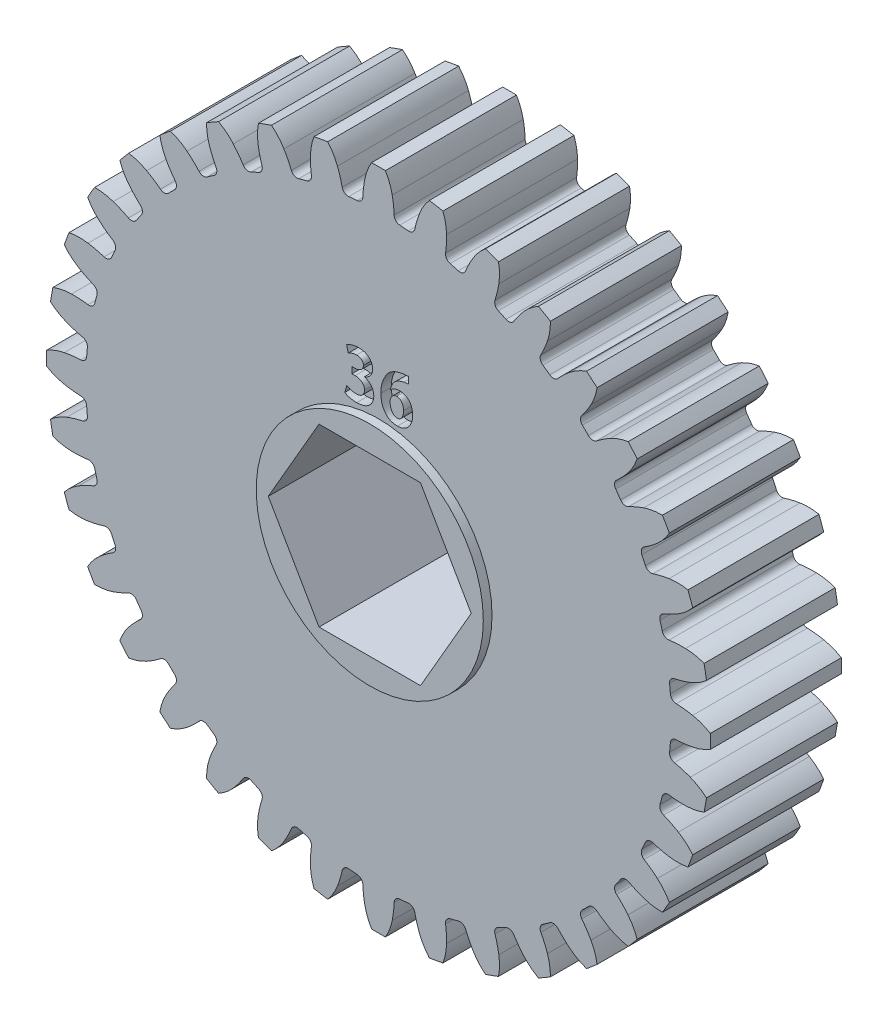
from build123d import *

# Parameters (mm, degrees)
SKETCH1_R            = 24.13
ROUND_STOCK_DEPTH    = 4.7625
SINGLE_TOOTH_DEPTH   = 36.429358236
TOOTH_PATTERN_COUNT  = 36
SKETCH4_R            = 8.255
TOPBEARINGBOSS_DEPTH = 0.635
ROUNDBORE_DEPTH      = 35.549194003
ROUNDBORE_DEPTH_BACK = 35.549194003
SKETCH5_R            = 6.3881
HEX_2_DEPTH          = 35.549194003
HEX_2_DEPTH_BACK     = 35.549194003
TOOTHCOUNT_DEPTH     = 0.762


with BuildPart() as part:
    # Sketch1 → Round Stock (new, symmetric)
    with BuildSketch(Plane.XY):
        Circle(SKETCH1_R)
    extrude(amount=ROUND_STOCK_DEPTH, both=True)

    # Sketch2 → Single Tooth (cut, through all)
    with BuildSketch(Plane.XY.offset(4.7625)):
        with BuildLine():
            ThreePointArc((-23.845709826, -3.693104775), (-24.038178065, -2.103068073), (-24.124740827, -0.503765842))
            ThreePointArc((-24.124740827, -0.503765842), (-23.502960299, -0.806631954), (-22.838222877, -0.997585))
            ThreePointArc((-22.838222877, -0.997585), (-22.243537068, -1.089742074), (-21.643459021, -1.135024237))
            ThreePointArc((-21.643459021, -1.135024237), (-21.351011668, -1.25921453), (-21.216180676, -1.546911048))
            ThreePointArc((-21.216180676, -1.546911048), (-21.191551715, -1.854020538), (-21.162477503, -2.160741118))
            ThreePointArc((-21.162477503, -2.160741118), (-21.245302134, -2.467480035), (-21.511741136, -2.640566549))
            ThreePointArc((-21.511741136, -2.640566549), (-22.094839484, -2.789363234), (-22.664487771, -2.983386341))
            ThreePointArc((-22.664487771, -2.983386341), (-23.28596769, -3.286868823), (-23.845709826, -3.693104775))
        make_face()
    single_tooth = extrude(amount=-SINGLE_TOOTH_DEPTH, mode=Mode.SUBTRACT)

    # Tooth Pattern: Single Tooth ×36 about axis
    tooth_pattern_axis = Axis((0, 0, 50), (0, 0, -1))
    for i in range(1, TOOTH_PATTERN_COUNT):
        add(single_tooth.rotate(tooth_pattern_axis, i * 360 / TOOTH_PATTERN_COUNT), mode=Mode.SUBTRACT)

    # Sketch4 → TopBearingBoss (add)
    with BuildSketch(Plane.XY.offset(4.7625)):
        Circle(SKETCH4_R)
    topbearingboss = extrude(amount=TOPBEARINGBOSS_DEPTH)

    # BottomBearingBoss: TopBearingBoss across plane
    add(topbearingboss.mirror(Plane.XY))

    # Sketch5 → RoundBore (cut, two sides: drawn at the far end of the back side and taken through both)
    with BuildSketch(Plane.XY.offset(-ROUNDBORE_DEPTH_BACK)):
        Circle(SKETCH5_R)
    extrude(amount=ROUNDBORE_DEPTH + ROUNDBORE_DEPTH_BACK, mode=Mode.SUBTRACT)

    # Sketch6 → Hex 2 (cut, two sides: drawn at the far end of the back side and taken through both)
    with BuildSketch(Plane.XY.offset(-HEX_2_DEPTH_BACK)):
        Polygon((3.688171255, 6.3881), (-3.688171255, 6.3881), (-7.376342509, 0), (-3.688171255, -6.3881), (3.688171255, -6.3881), (7.376342509, 0), align=None)
    extrude(amount=HEX_2_DEPTH + HEX_2_DEPTH_BACK, mode=Mode.SUBTRACT)

    # Sketch7 → ToothCount (cut)
    # profile 1 of 2: a face of its own
    with BuildSketch(Plane.XY.offset(4.7625)):
        with BuildLine():
            add(Edge.make_bspline(
                [(-2.196836906, 11.286278756), (-2.178915818, 11.297156055), (-2.141223827, 11.320033408), (-2.079049839, 11.350318156), (-2.010032763, 11.380926277), (-1.934762173, 11.410311036), (-1.854329878, 11.436168713), (-1.770263227, 11.455353767), (-1.683460919, 11.467360467), (-1.624659493, 11.4699095), (-1.594928356, 11.471198341)],
                knots=[0, 0, 0, 0, 0.789517344, 1.660528633, 2.603012169, 3.634206293, 4.703625655, 5.783272812, 6.879179917, 8, 8, 8, 8], degree=3))
            add(Edge.make_bspline(
                [(-1.594928356, 11.471198341), (-1.574460936, 11.470554656), (-1.534762177, 11.469306159), (-1.47713404, 11.463606686), (-1.423879336, 11.453477122), (-1.374283218, 11.441158677), (-1.328763048, 11.424951076), (-1.287884282, 11.404268463), (-1.250682209, 11.380957145), (-1.207632909, 11.345445565), (-1.162337367, 11.293728488), (-1.123737052, 11.221709264), (-1.099384551, 11.141044702), (-1.09719459, 11.08425001), (-1.096059578, 11.05481448)],
                knots=[0, 0, 0, 0, 1.002343817, 1.944153497, 2.831185645, 3.653858711, 4.444110717, 5.190523602, 5.892507091, 6.588768807, 7.916765639, 9.227316692, 10.562974774, 12, 12, 12, 12], degree=3))
            add(Edge.make_bspline(
                [(-1.096059578, 11.05481448), (-1.097577748, 11.03495677), (-1.100554269, 10.996023792), (-1.112699691, 10.940075039), (-1.129707477, 10.88785283), (-1.153031302, 10.839915598), (-1.182087741, 10.796142931), (-1.217177315, 10.756941781), (-1.256667361, 10.720722862), (-1.317771626, 10.680421456), (-1.398966259, 10.638714254), (-1.500733377, 10.602006649), (-1.605358693, 10.579218439), (-1.676201576, 10.576463643), (-1.711726998, 10.575082202)],
                knots=[0, 0, 0, 0, 0.826082647, 1.61961569, 2.370535654, 3.101700729, 3.826161143, 4.544435158, 5.281678469, 6.044172927, 7.575983875, 9.060899392, 10.526135799, 12, 12, 12, 12], degree=3))
            Line((-1.711726998, 10.575082202), (-1.930092284, 10.575741437))
            Line((-1.930092284, 10.575741437), (-1.930092284, 10.116465419))
            Line((-1.930092284, 10.116465419), (-1.697473218, 10.116465419))
            add(Edge.make_bspline(
                [(-1.697473218, 10.116465419), (-1.675382922, 10.115780753), (-1.631656679, 10.114425503), (-1.566825762, 10.10900903), (-1.504082821, 10.097360085), (-1.443435175, 10.082308135), (-1.384684626, 10.063366881), (-1.328755957, 10.038490645), (-1.274409443, 10.010378343), (-1.223022317, 9.977452657), (-1.175368974, 9.94023794), (-1.133494804, 9.897631047), (-1.097639058, 9.850707116), (-1.06816936, 9.798687509), (-1.044428595, 9.742258033), (-1.027698192, 9.680722473), (-1.015171602, 9.615212982), (-1.012808829, 9.569707458), (-1.011595023, 9.546330317)],
                knots=[0, 0, 0, 0, 1.060385101, 2.098960464, 3.117449411, 4.118233749, 5.096052482, 6.074383624, 7.051518727, 8.029280509, 8.998404297, 9.946146869, 10.88752235, 11.823439848, 12.807333282, 13.816263899, 14.87816903, 16, 16, 16, 16], degree=3))
            add(Edge.make_bspline(
                [(-1.011595023, 9.546330317), (-1.011865654, 9.528486901), (-1.012402597, 9.493084795), (-1.019998451, 9.441169552), (-1.031820529, 9.390924278), (-1.048936861, 9.342923732), (-1.071216041, 9.296953758), (-1.097218555, 9.252469587), (-1.12972688, 9.210937746), (-1.165309853, 9.170606621), (-1.206737658, 9.134079), (-1.25280534, 9.101643269), (-1.304179769, 9.074583526), (-1.360221912, 9.052217644), (-1.421012759, 9.033443704), (-1.487197189, 9.020778134), (-1.557974277, 9.011991685), (-1.606778844, 9.010140631), (-1.631881599, 9.009188537)],
                knots=[0, 0, 0, 0, 0.927962802, 1.841118252, 2.724136883, 3.611301861, 4.486942311, 5.380290724, 6.287036469, 7.227346462, 8.17619008, 9.154415755, 10.153127624, 11.190589993, 12.291550635, 13.459071236, 14.693066716, 16, 16, 16, 16], degree=3))
            add(Edge.make_bspline(
                [(-1.631881599, 9.009188537), (-1.665362091, 9.010379158), (-1.731664119, 9.012736967), (-1.829632894, 9.026224982), (-1.925378301, 9.043835659), (-2.016726815, 9.070022353), (-2.101885221, 9.099136161), (-2.178281918, 9.130048278), (-2.244835108, 9.161086619), (-2.284015729, 9.184838615), (-2.302319005, 9.195934389)],
                knots=[0, 0, 0, 0, 1.141993655, 2.261510849, 3.369504559, 4.459881496, 5.499111408, 6.438152545, 7.270381037, 8, 8, 8, 8], degree=3))
            Line((-2.302319005, 9.195934389), (-2.452261762, 8.684039438))
            add(Edge.make_bspline(
                [(-2.452261762, 8.684039438), (-2.428529877, 8.669357088), (-2.378233874, 8.638240153), (-2.292723153, 8.600830484), (-2.196474521, 8.564578926), (-2.089158441, 8.533792754), (-1.972966584, 8.507184261), (-1.849451555, 8.488462121), (-1.719665395, 8.476274829), (-1.631029969, 8.474350747), (-1.585690045, 8.473366516)],
                knots=[0, 0, 0, 0, 0.741190489, 1.570836841, 2.475795164, 3.475217062, 4.536537938, 5.643313588, 6.794477705, 8, 8, 8, 8], degree=3))
            add(Edge.make_bspline(
                [(-1.585690045, 8.473366516), (-1.537038073, 8.475140584), (-1.442349194, 8.478593362), (-1.304871939, 8.494333335), (-1.176257502, 8.519386582), (-1.056333753, 8.552935857), (-0.944728287, 8.594990317), (-0.842131695, 8.646565865), (-0.748066187, 8.706870718), (-0.663867654, 8.776373864), (-0.588711388, 8.852179588), (-0.522881774, 8.932982894), (-0.467152229, 9.018581512), (-0.421085215, 9.108670247), (-0.386357614, 9.203915239), (-0.360187511, 9.303221033), (-0.345085184, 9.4075216), (-0.342481777, 9.478536229), (-0.341157617, 9.514656109)],
                knots=[0, 0, 0, 0, 1.283230384, 2.49748659, 3.643929247, 4.734473942, 5.777057172, 6.783347331, 7.756557876, 8.716669339, 9.655743054, 10.566896716, 11.459630034, 12.344036494, 13.228461966, 14.127277565, 15.047484865, 16, 16, 16, 16], degree=3))
            add(Edge.make_bspline(
                [(-0.341157617, 9.514656109), (-0.342240041, 9.543504424), (-0.344354072, 9.599846698), (-0.355159789, 9.682148201), (-0.371536738, 9.760302853), (-0.393953784, 9.834546146), (-0.422410685, 9.904469492), (-0.456085487, 9.970635783), (-0.496495171, 10.031862162), (-0.542348497, 10.088757427), (-0.592137515, 10.141156982), (-0.645270919, 10.188796041), (-0.70070077, 10.232144743), (-0.759877188, 10.269770266), (-0.821926986, 10.302764875), (-0.886816291, 10.331072198), (-0.954333296, 10.355432631), (-1.001132443, 10.366768294), (-1.024792609, 10.372499246)],
                knots=[0, 0, 0, 0, 1.164005744, 2.273364363, 3.343604564, 4.382148734, 5.397114869, 6.385236831, 7.372083179, 8.350396341, 9.329473701, 10.284453012, 11.226859979, 12.164619053, 13.109320557, 14.058884727, 15.018633619, 16, 16, 16, 16], degree=3))
            Line((-1.024792609, 10.372499246), (-1.024619262, 10.381435327))
            add(Edge.make_bspline(
                [(-1.024619262, 10.381435327), (-1.000782815, 10.390213261), (-0.953943817, 10.407462042), (-0.887288613, 10.438702827), (-0.82492571, 10.473134486), (-0.766912611, 10.510610789), (-0.713304918, 10.551186008), (-0.663192206, 10.59389436), (-0.618612577, 10.640946391), (-0.578102521, 10.690491075), (-0.542541765, 10.742709757), (-0.51136231, 10.796953051), (-0.484940117, 10.853248236), (-0.462902155, 10.911387676), (-0.446558127, 10.97178571), (-0.434690991, 11.033989365), (-0.427235547, 11.098187454), (-0.426164403, 11.141678607), (-0.425622172, 11.16369457)],
                knots=[0, 0, 0, 0, 1.153913132, 2.267457648, 3.341260607, 4.389305308, 5.402891048, 6.394955316, 7.377659085, 8.344009373, 9.300538721, 10.245296245, 11.184325342, 12.123779964, 13.067108642, 14.023794665, 14.999611132, 16, 16, 16, 16], degree=3))
            add(Edge.make_bspline(
                [(-0.425622172, 11.16369457), (-0.426366913, 11.192331555), (-0.427840032, 11.248976366), (-0.440013671, 11.332106293), (-0.459591608, 11.411821864), (-0.488010301, 11.487580561), (-0.522487963, 11.560696423), (-0.566830535, 11.62934768), (-0.617838522, 11.695132733), (-0.67648039, 11.757205999), (-0.743001822, 11.814036857), (-0.817489119, 11.863701359), (-0.899346405, 11.906174453), (-0.988972012, 11.941155134), (-1.086136015, 11.968304764), (-1.190339529, 11.989811767), (-1.302292027, 12.002801474), (-1.379554875, 12.005584906), (-1.419400452, 12.007020362)],
                knots=[0, 0, 0, 0, 0.938614469, 1.856607385, 2.748736139, 3.624980026, 4.505635583, 5.394024719, 6.298603057, 7.232244148, 8.189000026, 9.161181486, 10.161216018, 11.207242686, 12.309896165, 13.465529691, 14.6929367, 16, 16, 16, 16], degree=3))
            add(Edge.make_bspline(
                [(-1.419400452, 12.007020362), (-1.465622688, 12.005609431), (-1.556286215, 12.002841931), (-1.689776389, 11.989048547), (-1.817579323, 11.965815744), (-1.938844915, 11.935282334), (-2.050442449, 11.897929795), (-2.151912406, 11.860147691), (-2.2402274, 11.817159271), (-2.293082812, 11.784809656), (-2.318156109, 11.769463801)],
                knots=[0, 0, 0, 0, 1.17932827, 2.313217001, 3.419264874, 4.49021776, 5.499784981, 6.419836909, 7.250409829, 8, 8, 8, 8], degree=3))
            Line((-2.318156109, 11.769463801), (-2.196836906, 11.286278756))
        make_face()
    # profile 2 of 2: a face of its own
    with BuildSketch(Plane.XY.offset(4.7625)):
        with BuildLine():
            add(Edge.make_bspline(
                [(2.16522585, 12.011638873), (2.116090977, 12.008719227), (2.019932735, 12.003005404), (1.879031609, 11.988190007), (1.744404434, 11.969563186), (1.615928082, 11.944746803), (1.493296301, 11.916256978), (1.377056529, 11.881820359), (1.267150023, 11.842813368), (1.163127743, 11.799470705), (1.06544998, 11.750394794), (0.973311698, 11.69728536), (0.888067039, 11.638121618), (0.808393868, 11.574734504), (0.735107827, 11.506119033), (0.66828399, 11.43244516), (0.607036737, 11.354374643), (0.5355791, 11.244205041), (0.457579729, 11.10304908), (0.374719808, 10.933851292), (0.305310899, 10.765916944), (0.251550554, 10.59885633), (0.208961641, 10.433802856), (0.182167599, 10.269504161), (0.16815263, 10.10659293), (0.169993557, 9.998589698), (0.170908748, 9.944897436)],
                knots=[0, 0, 0, 0, 1.090744659, 2.134616076, 3.139087949, 4.101859546, 5.033610514, 5.928252281, 6.787073956, 7.617306137, 8.423946315, 9.20820989, 9.972212763, 10.721358476, 11.46286786, 12.194455914, 12.923864343, 13.659388525, 15.102127992, 16.495300966, 17.833290996, 19.125159406, 20.3819783, 21.607356425, 22.810531475, 24, 24, 24, 24], degree=3))
            add(Edge.make_bspline(
                [(0.170908748, 9.944897436), (0.171997744, 9.892514966), (0.174134233, 9.78974636), (0.188649927, 9.639315699), (0.212957804, 9.496400409), (0.246768717, 9.360970325), (0.289364177, 9.232497762), (0.342284126, 9.11153069), (0.404530359, 8.997823002), (0.476280219, 8.892606751), (0.556253323, 8.796074997), (0.646930208, 8.712892587), (0.74493695, 8.640290295), (0.853419233, 8.582462824), (0.969543075, 8.535086828), (1.095117815, 8.50193965), (1.228807739, 8.479552879), (1.321205658, 8.475463604), (1.368589744, 8.473366516)],
                knots=[0, 0, 0, 0, 1.177116803, 2.309372851, 3.392628795, 4.432051096, 5.443402761, 6.430645545, 7.395204453, 8.352184711, 9.288881539, 10.205312589, 11.110962038, 12.02225958, 12.960363956, 13.923249514, 14.93498766, 16, 16, 16, 16], degree=3))
            add(Edge.make_bspline(
                [(1.368589744, 8.473366516), (1.411342146, 8.475627545), (1.494855157, 8.480044265), (1.616154334, 8.500289552), (1.730496415, 8.530200645), (1.837131605, 8.572251106), (1.936937945, 8.623784428), (2.029502145, 8.686221567), (2.114080207, 8.760027545), (2.191092047, 8.843287057), (2.260069439, 8.934026113), (2.320041648, 9.030515295), (2.371318782, 9.131318333), (2.412946872, 9.237013093), (2.445952513, 9.347143913), (2.469760612, 9.462156485), (2.48434098, 9.58159847), (2.487038427, 9.66286909), (2.488404977, 9.704041478)],
                knots=[0, 0, 0, 0, 1.104921001, 2.158364753, 3.169783988, 4.151903943, 5.11232811, 6.06555167, 7.028006494, 8.004772461, 8.989828801, 9.967123232, 10.935061221, 11.906609782, 12.896893828, 13.900706794, 14.936480177, 16, 16, 16, 16], degree=3))
            add(Edge.make_bspline(
                [(2.488404977, 9.704041478), (2.487102095, 9.745881011), (2.48455711, 9.827608231), (2.469523147, 9.946206312), (2.448078109, 10.057696411), (2.418845379, 10.161816269), (2.379826724, 10.257961894), (2.334938543, 10.347771075), (2.280123752, 10.429155525), (2.218771813, 10.503330003), (2.151003727, 10.569225308), (2.077669646, 10.626225584), (2.000468227, 10.67560012), (1.917922724, 10.715240078), (1.831199903, 10.746308044), (1.739908608, 10.76882408), (1.644189086, 10.782885995), (1.578699174, 10.785112677), (1.545437406, 10.78624359)],
                knots=[0, 0, 0, 0, 1.24489772, 2.431720048, 3.552250136, 4.621151083, 5.643244016, 6.635503114, 7.602998542, 8.555771906, 9.495326128, 10.409157675, 11.315198569, 12.216760831, 13.127634607, 14.051465654, 15.010356011, 16, 16, 16, 16], degree=3))
            add(Edge.make_bspline(
                [(1.545437406, 10.78624359), (1.509533826, 10.784938902), (1.439385005, 10.782389788), (1.337057078, 10.767272191), (1.240760281, 10.741486208), (1.151132542, 10.705717889), (1.068167776, 10.662105476), (0.992734761, 10.610948247), (0.923863705, 10.553647343), (0.884193251, 10.509806048), (0.864441931, 10.48797813)],
                knots=[0, 0, 0, 0, 1.123065688, 2.194258491, 3.227237041, 4.233902505, 5.206347761, 6.152747248, 7.080280743, 8, 8, 8, 8], degree=3))
            add(Edge.make_bspline(
                [(0.864441931, 10.48797813), (0.861826889, 10.493829502), (0.855215586, 10.508622843), (0.85772762, 10.53916287), (0.865853204, 10.579165289), (0.882804349, 10.630026603), (0.904993373, 10.69229104), (0.935706115, 10.765181241), (0.973828248, 10.848981827), (1.016388606, 10.942574064), (1.070734007, 11.038505241), (1.14235549, 11.127327846), (1.228216905, 11.208074416), (1.328312123, 11.280592801), (1.443170541, 11.34450425), (1.57161643, 11.401286865), (1.714859819, 11.449432081), (1.81621044, 11.473758241), (1.868778281, 11.486375566)],
                knots=[0, 0, 0, 0, 0.198488592, 0.501815517, 0.930396636, 1.486405783, 2.175509351, 3.003826712, 3.963476477, 5.061300956, 6.225944111, 7.408084015, 8.622350983, 9.910236386, 11.271529384, 12.734443746, 14.306243838, 16, 16, 16, 16], degree=3))
            add(Edge.make_bspline(
                [(1.868778281, 11.486375566), (1.896037754, 11.489802634), (1.948727039, 11.496426745), (2.025275164, 11.503946619), (2.096841265, 11.507751889), (2.142845181, 11.508911348), (2.165064103, 11.509471342)],
                knots=[0, 0, 0, 0, 1.108691902, 2.142968185, 3.103092764, 4, 4, 4, 4], degree=3))
            Line((2.165064103, 11.509471342), (2.16522585, 12.011638873))
        make_face()
        with BuildLine():
            add(Edge.make_bspline(
                [(1.364390101, 8.966956259), (1.343933288, 8.968112384), (1.304099193, 8.970363622), (1.246761536, 8.983795791), (1.192744728, 9.001766759), (1.142651247, 9.027836534), (1.09709366, 9.061470024), (1.054172614, 9.100710528), (1.015338669, 9.14718621), (0.980559892, 9.200086347), (0.949988787, 9.258307654), (0.922069086, 9.320030701), (0.89901414, 9.385904348), (0.880172382, 9.455247477), (0.864130816, 9.528081861), (0.852237163, 9.604533058), (0.845230106, 9.684790248), (0.843096861, 9.739443245), (0.842006033, 9.767389894)],
                knots=[0, 0, 0, 0, 0.926139194, 1.803404789, 2.657055295, 3.499062306, 4.347817451, 5.214844897, 6.126713206, 7.082564733, 8.076278264, 9.101781735, 10.147689039, 11.232705617, 12.354143743, 13.523397599, 14.733596634, 16, 16, 16, 16], degree=3))
            add(Edge.make_bspline(
                [(0.842006033, 9.767389894), (0.843400424, 9.790740389), (0.846108252, 9.83608572), (0.856051053, 9.901424665), (0.870421781, 9.962001371), (0.889767722, 10.017539913), (0.912544191, 10.069083826), (0.941158122, 10.115098495), (0.973655884, 10.157020519), (1.023219254, 10.203513648), (1.087686743, 10.252267551), (1.168341482, 10.295472183), (1.250085976, 10.322435927), (1.305274422, 10.325478053), (1.33229638, 10.326967572)],
                knots=[0, 0, 0, 0, 1.019565375, 1.979937854, 2.877887155, 3.730215488, 4.541457296, 5.32940169, 6.087354344, 6.847064817, 8.285754454, 9.59863703, 10.824218969, 12, 12, 12, 12], degree=3))
            add(Edge.make_bspline(
                [(1.33229638, 10.326967572), (1.351474642, 10.325834593), (1.388753617, 10.323632294), (1.44305617, 10.313580775), (1.493733116, 10.297764116), (1.541238934, 10.276753001), (1.584380899, 10.249129523), (1.624500604, 10.216605046), (1.660755411, 10.17796565), (1.704900406, 10.119321709), (1.750999942, 10.035939583), (1.789524081, 9.924290653), (1.813925486, 9.801652379), (1.816588548, 9.716040247), (1.817967572, 9.671707391)],
                knots=[0, 0, 0, 0, 0.758000342, 1.473411723, 2.17385435, 2.850193177, 3.517607678, 4.19036856, 4.884537793, 5.603629569, 7.084853698, 8.623030215, 10.251290901, 12, 12, 12, 12], degree=3))
            add(Edge.make_bspline(
                [(1.817967572, 9.671707391), (1.816683392, 9.624107138), (1.814207354, 9.532328701), (1.792270634, 9.400774435), (1.756168448, 9.281139142), (1.713525632, 9.191277054), (1.672973869, 9.127216021), (1.638391419, 9.086386781), (1.601280535, 9.05079452), (1.56050791, 9.021357346), (1.51613708, 8.997965359), (1.468093235, 8.981990661), (1.417334504, 8.969858491), (1.382082821, 8.967941305), (1.364390101, 8.966956259)],
                knots=[0, 0, 0, 0, 1.837349789, 3.542609231, 5.133420927, 6.649529765, 7.368219049, 8.055651448, 8.710666968, 9.349619728, 9.991783468, 10.639263455, 11.300856702, 12, 12, 12, 12], degree=3))
        make_face(mode=Mode.SUBTRACT)
    extrude(amount=-TOOTHCOUNT_DEPTH, mode=Mode.SUBTRACT)


solid = part.part
